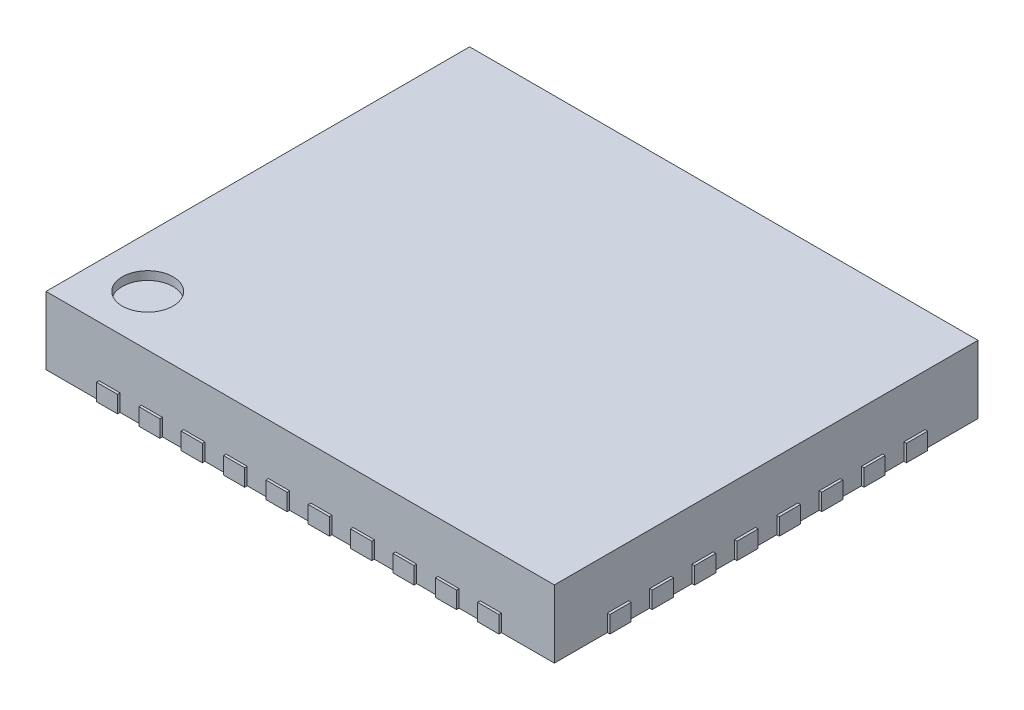
from build123d import *

# Parameters (mm, degrees)
SKETCH1_W           = 6
SKETCH1_H           = 5
BOSS_EXTRUDE1_DEPTH = 0.8
SKETCH2_R           = 0.3
CUT_EXTRUDE1_DEPTH  = 0.1
SKETCH3_W           = 0.25
SKETCH3_H           = 0.2
BOSS_EXTRUDE2_DEPTH = 0.03
LPATTERN1_COUNT     = 2
LPATTERN1_PITCH     = 5.03
SKETCH4_W           = 0.25
SKETCH4_H           = 0.2
BOSS_EXTRUDE3_DEPTH = 0.03
LPATTERN2_COUNT     = 2
LPATTERN2_PITCH     = 6.03


with BuildPart() as part:
    # Sketch1 → Boss-Extrude1 (new body)
    with BuildSketch(Plane(origin=(0, 0, 0), x_dir=(1, 0, 0), z_dir=(0, 1, 0))):
        Rectangle(SKETCH1_W, SKETCH1_H)
    extrude(amount=BOSS_EXTRUDE1_DEPTH)

    # Sketch2 → Cut-Extrude1 (cut)
    with BuildSketch(Plane(origin=(0, 0.8, 0), x_dir=(1, 0, 0), z_dir=(0, 1, 0))):
        with Locations((-2.4, -1.9)):
            Circle(SKETCH2_R)
    extrude(amount=-CUT_EXTRUDE1_DEPTH, mode=Mode.SUBTRACT)

    # Sketch3 → Boss-Extrude2 (add)
    with BuildSketch(Plane.XY.offset(2.5)):
        with Locations((-0.25, 0.1)):
            Rectangle(SKETCH3_W, SKETCH3_H)
        with Locations((0.25, 0.1)):
            Rectangle(SKETCH3_W, SKETCH3_H)
        with Locations((0.75, 0.1)):
            Rectangle(SKETCH3_W, SKETCH3_H)
        with Locations((1.25, 0.1)):
            Rectangle(SKETCH3_W, SKETCH3_H)
        with Locations((1.75, 0.1)):
            Rectangle(SKETCH3_W, SKETCH3_H)
        with Locations((2.25, 0.1)):
            Rectangle(SKETCH3_W, SKETCH3_H)
        with Locations((-0.75, 0.1)):
            Rectangle(SKETCH3_W, SKETCH3_H)
        with Locations((-1.25, 0.1)):
            Rectangle(SKETCH3_W, SKETCH3_H)
        with Locations((-1.75, 0.1)):
            Rectangle(SKETCH3_W, SKETCH3_H)
        with Locations((-2.25, 0.1)):
            Rectangle(SKETCH3_W, SKETCH3_H)
    boss_extrude2 = extrude(amount=BOSS_EXTRUDE2_DEPTH)

    # LPattern1: Boss-Extrude2 ×2
    with Locations(*[(0, 0, -i * LPATTERN1_PITCH) for i in range(1, LPATTERN1_COUNT)]):
        add(boss_extrude2)

    # Sketch4 → Boss-Extrude3 (add)
    with BuildSketch(Plane(origin=(3, 0, 0), x_dir=(0, 0, -1), z_dir=(1, 0, 0))):
        with Locations((-0.25, 0.1)):
            Rectangle(SKETCH4_W, SKETCH4_H)
        with Locations((0.25, 0.1)):
            Rectangle(SKETCH4_W, SKETCH4_H)
        with Locations((0.75, 0.1)):
            Rectangle(SKETCH4_W, SKETCH4_H)
        with Locations((1.25, 0.1)):
            Rectangle(SKETCH4_W, SKETCH4_H)
        with Locations((1.75, 0.1)):
            Rectangle(SKETCH4_W, SKETCH4_H)
        with Locations((-0.75, 0.1)):
            Rectangle(SKETCH4_W, SKETCH4_H)
        with Locations((-1.25, 0.1)):
            Rectangle(SKETCH4_W, SKETCH4_H)
        with Locations((-1.75, 0.1)):
            Rectangle(SKETCH4_W, SKETCH4_H)
    boss_extrude3 = extrude(amount=BOSS_EXTRUDE3_DEPTH)

    # LPattern2: Boss-Extrude3 ×2
    with Locations(*[(-i * LPATTERN2_PITCH, 0, 0) for i in range(1, LPATTERN2_COUNT)]):
        add(boss_extrude3)


solid = part.part
